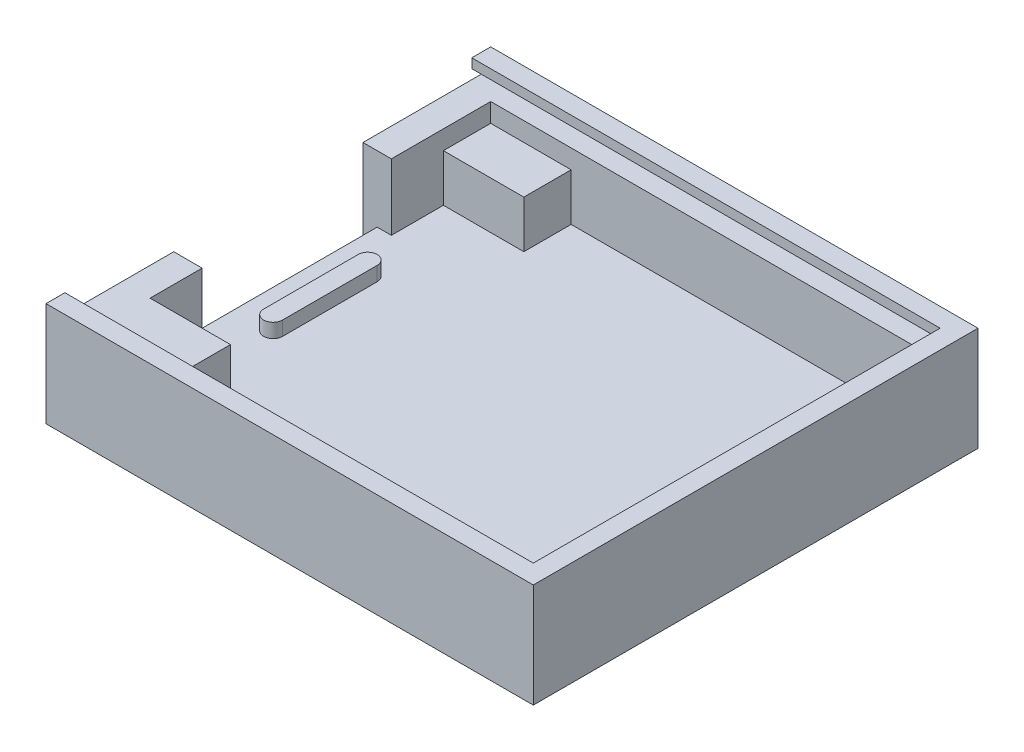
from build123d import *

# Parameters (mm, degrees)
CROQUIS1_W               = 51.5
CROQUIS1_H               = 47
SALIENTE_EXTRUIR1_DEPTH  = 2
SALIENTE_EXTRUIR11_DEPTH = 1.5
CROQUIS3_W               = 51.5
CROQUIS3_H               = 47
CROQUIS3_W_2             = 45.5
CROQUIS3_H_2             = 41
SALIENTE_EXTRUIR10_DEPTH = 7
CROQUIS4_W               = 3
CROQUIS4_H               = 20
CORTAR_EXTRUIR3_DEPTH    = 7
CROQUIS5_W               = 8.5
CROQUIS5_H               = 5
SALIENTE_EXTRUIR12_DEPTH = 7
CROQUIS6_R               = 0.5
CORTAR_EXTRUIR2_DEPTH    = 12.5
CROQUIS8_W               = 8.5
CROQUIS8_H               = 5
SALIENTE_EXTRUIR13_DEPTH = 5
SALIENTE_EXTRUIR14_DEPTH = 2
CROQUIS10_W              = 50.5
CROQUIS10_H              = 1
SALIENTE_EXTRUIR15_DEPTH = 1
CROQUIS11_W              = 50.5
CROQUIS11_H              = 1
SALIENTE_EXTRUIR16_DEPTH = 1
CROQUIS12_W              = 43
CROQUIS12_H              = 1
SALIENTE_EXTRUIR17_DEPTH = 1
CROQUIS13_W              = 1.5
CROQUIS13_H              = 20
CORTAR_EXTRUIR4_DEPTH    = 3


with BuildPart() as part:
    # Croquis1 → Saliente-Extruir1 (new body)
    with BuildSketch(Plane(origin=(0, 0, 0), x_dir=(1, 0, 0), z_dir=(0, 1, 0))):
        with Locations((-25.75, 23.5)):
            Rectangle(CROQUIS1_W, CROQUIS1_H)
    extrude(amount=SALIENTE_EXTRUIR1_DEPTH)

    # Croquis2 → Saliente-Extruir11 (add)
    with BuildSketch(Plane(origin=(0, 2, 0), x_dir=(1, 0, 0), z_dir=(0, 1, 0))):
        with BuildLine():
            Line((-45, 28.5), (-45, 18.5))
            ThreePointArc((-45, 18.5), (-46, 17.5), (-47, 18.5))
            Line((-47, 18.5), (-47, 28.5))
            ThreePointArc((-47, 28.5), (-46, 29.5), (-45, 28.5))
        make_face()
    extrude(amount=SALIENTE_EXTRUIR11_DEPTH)

    # Croquis3 → Saliente-Extruir10 (add)
    with BuildSketch(Plane(origin=(0, 2, 0), x_dir=(1, 0, 0), z_dir=(0, 1, 0))):
        with Locations((-25.75, 23.5)):
            Rectangle(CROQUIS3_W, CROQUIS3_H)
        with Locations((-25.75, 23.5)):
            Rectangle(CROQUIS3_W_2, CROQUIS3_H_2, mode=Mode.SUBTRACT)
    extrude(amount=SALIENTE_EXTRUIR10_DEPTH)

    # Croquis4 → Cortar-Extruir3 (cut)
    with BuildSketch(Plane(origin=(0, 9, 0), x_dir=(1, 0, 0), z_dir=(0, 1, 0))):
        with Locations((-50, 23.5)):
            Rectangle(CROQUIS4_W, CROQUIS4_H)
    extrude(amount=-CORTAR_EXTRUIR3_DEPTH, mode=Mode.SUBTRACT)

    # Croquis5 → Saliente-Extruir12 (add)
    with BuildSketch(Plane(origin=(0, 2, 0), x_dir=(1, 0, 0), z_dir=(0, 1, 0))):
        with Locations((-44.25, 5.5)):
            Rectangle(CROQUIS5_W, CROQUIS5_H)
    extrude(amount=SALIENTE_EXTRUIR12_DEPTH)

    # Croquis6 → Cortar-Extruir2 (cut, through all)
    with BuildSketch(Plane(origin=(-40, 0, 0), x_dir=(0, 0, -1), z_dir=(1, 0, 0))):
        with Locations((5.5, 5.5)):
            Circle(CROQUIS6_R)
    extrude(amount=-CORTAR_EXTRUIR2_DEPTH, mode=Mode.SUBTRACT)

    # Croquis8 → Saliente-Extruir13 (add)
    with BuildSketch(Plane(origin=(0, 2, 0), x_dir=(1, 0, 0), z_dir=(0, 1, 0))):
        with Locations((-44.25, 41.5)):
            Rectangle(CROQUIS8_W, CROQUIS8_H)
    extrude(amount=SALIENTE_EXTRUIR13_DEPTH)

    # Croquis9 → Saliente-Extruir14 (add)
    with BuildSketch(Plane(origin=(0, 9, 0), x_dir=(1, 0, 0), z_dir=(0, 1, 0))):
        Polygon((-51.5, 1), (-1, 1), (-1, 46), (-51.5, 46), (-51.5, 47), (0, 47), (0, 0), (-51.5, 0), align=None)
    extrude(amount=SALIENTE_EXTRUIR14_DEPTH)

    # Croquis10 → Saliente-Extruir15 (add)
    with BuildSketch(Plane.XY.offset(-46)):
        with Locations((-26.25, 10.5)):
            Rectangle(CROQUIS10_W, CROQUIS10_H)
    extrude(amount=SALIENTE_EXTRUIR15_DEPTH)

    # Croquis11 → Saliente-Extruir16 (add)
    with BuildSketch(Plane(origin=(0, 0, -1), x_dir=(-1, 0, 0), z_dir=(0, 0, -1))):
        with Locations((26.25, 10.5)):
            Rectangle(CROQUIS11_W, CROQUIS11_H)
    extrude(amount=SALIENTE_EXTRUIR16_DEPTH)

    # Croquis12 → Saliente-Extruir17 (add)
    with BuildSketch(Plane.ZY.offset(1)):
        with Locations((-23.5, 10.5)):
            Rectangle(CROQUIS12_W, CROQUIS12_H)
    extrude(amount=SALIENTE_EXTRUIR17_DEPTH)

    # Croquis13 → Cortar-Extruir4 (cut, through all)
    with BuildSketch(Plane(origin=(0, 2, 0), x_dir=(1, 0, 0), z_dir=(0, 1, 0))):
        with Locations((-50.75, 23.5)):
            Rectangle(CROQUIS13_W, CROQUIS13_H)
    extrude(amount=-CORTAR_EXTRUIR4_DEPTH, mode=Mode.SUBTRACT)


solid = part.part
